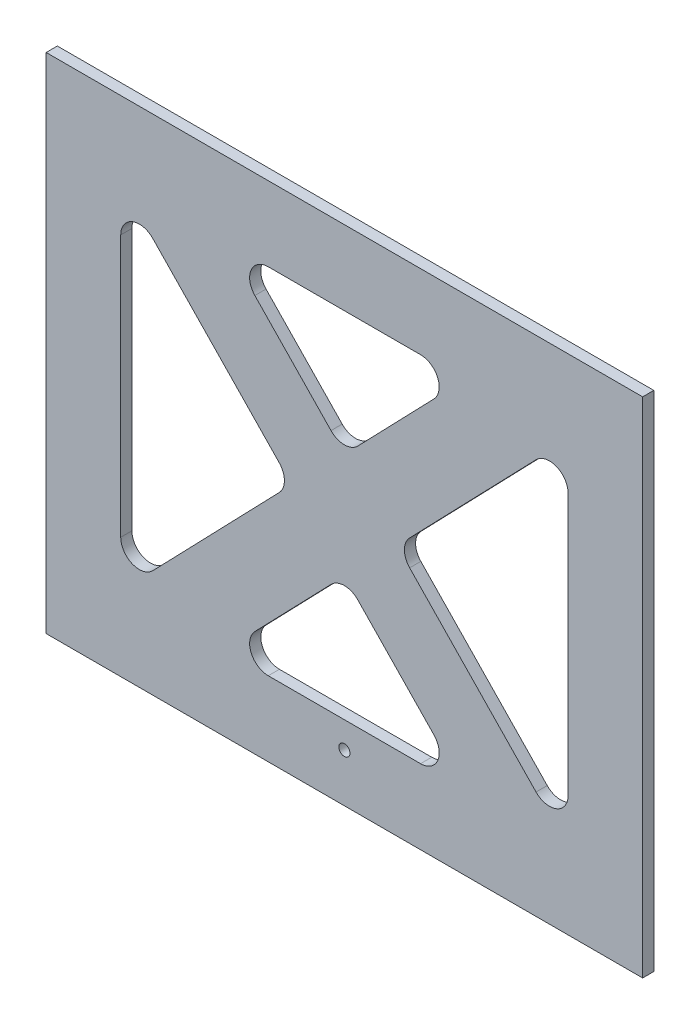
from build123d import *

# Parameters (mm, degrees)
SKETCH1_W           = 160
SKETCH1_H           = 135
BOSS_EXTRUDE1_DEPTH = 3
CUT_EXTRUDE1_DEPTH  = 20


with BuildPart() as part:
    # Sketch1 → Boss-Extrude1 (new body)
    with BuildSketch(Plane.XY.offset(152)):
        with Locations((0, 12.91714511)):
            Rectangle(SKETCH1_W, SKETCH1_H)
        with BuildLine():
            Line((-60, -22.204596664), (-60, 48.038886885))
            ThreePointArc((-60, 48.038886885), (-56.872665603, 52.674954566), (-51.402750584, 51.511608676))
            Line((-51.402750584, 51.511608676), (-17.49683417, 16.389866902))
            ThreePointArc((-17.49683417, 16.389866902), (-16.094083586, 12.91714511), (-17.49683417, 9.444423319))
            Line((-17.49683417, 9.444423319), (-51.402750584, -25.677318456))
            ThreePointArc((-51.402750584, -25.677318456), (-56.872665603, -26.840664345), (-60, -22.204596664))
        make_face(mode=Mode.SUBTRACT)
        with BuildLine():
            Line((20.424315219, 60.41714511), (-20.424315219, 60.41714511))
            ThreePointArc((-20.424315219, 60.41714511), (-25.026684661, 57.371165459), (-24.021564635, 51.944423319))
            Line((-24.021564635, 51.944423319), (-3.597249416, 30.787716735))
            ThreePointArc((-3.597249416, 30.787716735), (0, 29.260438526), (3.597249416, 30.787716735))
            Line((3.597249416, 30.787716735), (24.021564635, 51.944423319))
            ThreePointArc((24.021564635, 51.944423319), (25.026684661, 57.371165459), (20.424315219, 60.41714511))
        make_face(mode=Mode.SUBTRACT)
        with BuildLine():
            Line((51.402750584, 51.511608676), (17.49683417, 16.389866902))
            ThreePointArc((17.49683417, 16.389866902), (16.094083586, 12.91714511), (17.49683417, 9.444423319))
            Line((17.49683417, 9.444423319), (51.402750584, -25.677318456))
            ThreePointArc((51.402750584, -25.677318456), (56.872665603, -26.840664345), (60, -22.204596664))
            Line((60, -22.204596664), (60, 48.038886885))
            ThreePointArc((60, 48.038886885), (56.872665603, 52.674954566), (51.402750584, 51.511608676))
        make_face(mode=Mode.SUBTRACT)
        with BuildLine():
            Line((-24.021564635, -26.110133098), (-3.597249416, -4.953426514))
            ThreePointArc((-3.597249416, -4.953426514), (0, -3.426148305), (3.597249416, -4.953426514))
            Line((3.597249416, -4.953426514), (24.021564635, -26.110133098))
            ThreePointArc((24.021564635, -26.110133098), (25.026684661, -31.536875238), (20.424315219, -34.58285489))
            Line((20.424315219, -34.58285489), (-20.424315219, -34.58285489))
            ThreePointArc((-20.424315219, -34.58285489), (-25.026684661, -31.536875238), (-24.021564635, -26.110133098))
        make_face(mode=Mode.SUBTRACT)
    extrude(amount=BOSS_EXTRUDE1_DEPTH)

    # Sketch2 → Cut-Extrude1 (cut)
    with BuildSketch(Plane.XY.offset(155)):
        with BuildLine():
            ThreePointArc((1.5, -41.631936217), (0, -40.131936217), (-1.5, -41.631936217))
            Line((-1.5, -41.631936217), (1.5, -41.631936217))
        make_face()
        with BuildLine():
            Line((1.5, -41.631936217), (-1.5, -41.631936217))
            ThreePointArc((-1.5, -41.631936217), (0, -43.131936217), (1.5, -41.631936217))
        make_face()
    extrude(amount=-CUT_EXTRUDE1_DEPTH, mode=Mode.SUBTRACT)


solid = part.part
